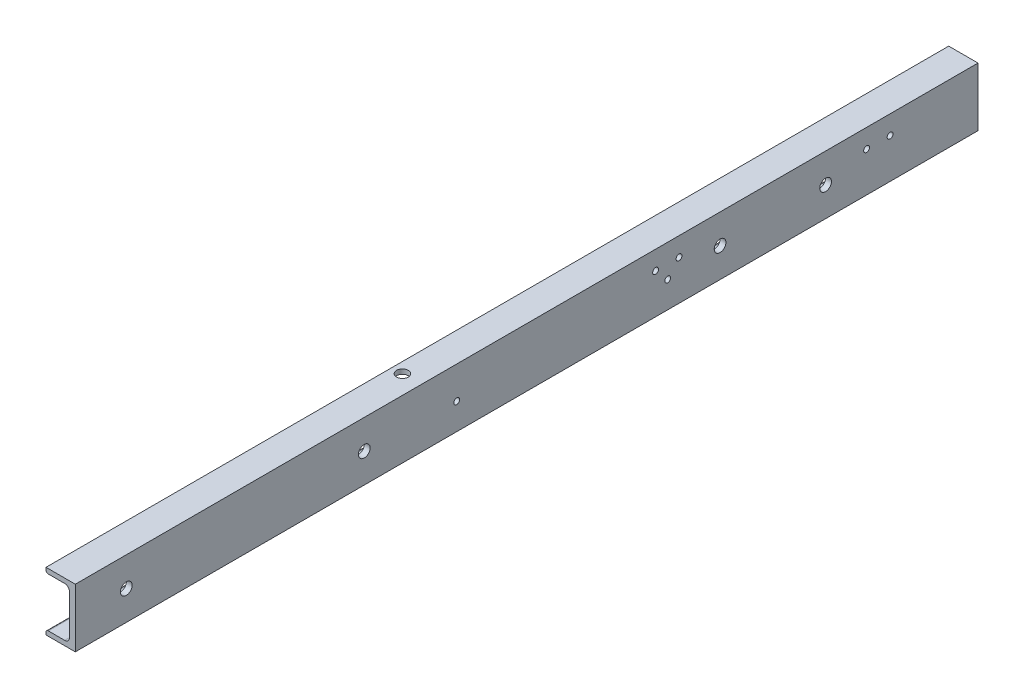
from build123d import *

# Parameters (mm, degrees)
STRUCTURAL_MEMBER1_DEPTH       = 770
F_10_0_10_DIAMETER_HOLE1_D     = 10
F_10_0_10_DIAMETER_HOLE1_DEPTH = 11
F_10_0_10_DIAMETER_HOLE1_TIP   = 3.004303095
SKETCH28_R                     = 5
CUT_EXTRUDE1_DEPTH             = 773.026553947
F_10_0_10_DIAMETER_HOLE2_D     = 10
F_10_0_10_DIAMETER_HOLE2_DEPTH = 11
F_10_0_10_DIAMETER_HOLE2_TIP   = 3.004303095
F_5_0_5_DIAMETER_HOLE1_D       = 5
F_5_0_5_DIAMETER_HOLE1_DEPTH   = 11
F_5_0_5_DIAMETER_HOLE1_TIP     = 1.502151548
SKETCH33_R                     = 2.5
CUT_EXTRUDE2_DEPTH             = 10


with BuildPart() as part:
    # Sketch11 → Structural Member1 (new body)
    with BuildSketch(Plane(origin=(0, 0, 0), x_dir=(-1, 0, 0), z_dir=(0, 0, -1))):
        with BuildLine():
            Line((25, 50), (0, 50))
            Line((0, 50), (0, 0))
            Line((0, 0), (25, 0))
            Line((25, 0), (25, 2))
            ThreePointArc((25, 2), (24.414213562, 3.414213562), (23, 4))
            Line((23, 4), (9, 4))
            ThreePointArc((9, 4), (6.171572875, 5.171572875), (5, 8))
            Line((5, 8), (5, 42))
            ThreePointArc((5, 42), (6.171572875, 44.828427125), (9, 46))
            Line((9, 46), (23, 46))
            ThreePointArc((23, 46), (24.414213562, 46.585786438), (25, 48))
            Line((25, 48), (25, 50))
        make_face()
    extrude(amount=STRUCTURAL_MEMBER1_DEPTH)

    # Ø10.0 (10) Diameter Hole1
    with Locations(Plane(origin=(0, 0, 0), x_dir=(0, 0, -1), z_dir=(1, 0, 0))):
        with Locations((550, 25), (640, 25)):
            Hole(F_10_0_10_DIAMETER_HOLE1_D / 2, depth=F_10_0_10_DIAMETER_HOLE1_DEPTH)
            with Locations((0, 0, -(F_10_0_10_DIAMETER_HOLE1_DEPTH + F_10_0_10_DIAMETER_HOLE1_TIP / 2))):  # 118° drill point
                Cone(0, F_10_0_10_DIAMETER_HOLE1_D / 2, F_10_0_10_DIAMETER_HOLE1_TIP, mode=Mode.SUBTRACT)

    # Sketch28 → Cut-Extrude1 (cut, through all)
    with BuildSketch(Plane.XZ):
        with Locations((-16, -295)):
            Circle(SKETCH28_R)
    extrude(amount=-CUT_EXTRUDE1_DEPTH, mode=Mode.SUBTRACT)

    # Ø10.0 (10) Diameter Hole2
    with Locations(Plane(origin=(0, 0, 0), x_dir=(0, 0, -1), z_dir=(1, 0, 0))):
        with Locations((43.5, 25), (246.5, 25)):
            Hole(F_10_0_10_DIAMETER_HOLE2_D / 2, depth=F_10_0_10_DIAMETER_HOLE2_DEPTH)
            with Locations((0, 0, -(F_10_0_10_DIAMETER_HOLE2_DEPTH + F_10_0_10_DIAMETER_HOLE2_TIP / 2))):  # 118° drill point
                Cone(0, F_10_0_10_DIAMETER_HOLE2_D / 2, F_10_0_10_DIAMETER_HOLE2_TIP, mode=Mode.SUBTRACT)

    # Ø5.0 (5) Diameter Hole1
    with Locations(Plane(origin=(0, 0, 0), x_dir=(0, 0, -1), z_dir=(1, 0, 0))):
        with Locations((515, 33.95), (675, 33.95), (495, 33.95), (695, 33.95)):
            Hole(F_5_0_5_DIAMETER_HOLE1_D / 2, depth=F_5_0_5_DIAMETER_HOLE1_DEPTH)
            with Locations((0, 0, -(F_5_0_5_DIAMETER_HOLE1_DEPTH + F_5_0_5_DIAMETER_HOLE1_TIP / 2))):  # 118° drill point
                Cone(0, F_5_0_5_DIAMETER_HOLE1_D / 2, F_5_0_5_DIAMETER_HOLE1_TIP, mode=Mode.SUBTRACT)

    # Sketch33 → Cut-Extrude2 (cut)
    with BuildSketch(Plane(origin=(0, 0, 0), x_dir=(0, 0, -1), z_dir=(1, 0, 0))):
        with Locations(Location((505.309927761, 22.5, 0), (0, 0, 90))):
            Circle(SKETCH33_R)
        with Locations(Location((325.309927761, 22.5, 0), (0, 0, 90))):
            Circle(SKETCH33_R)
    extrude(amount=-CUT_EXTRUDE2_DEPTH, mode=Mode.SUBTRACT)


solid = part.part
